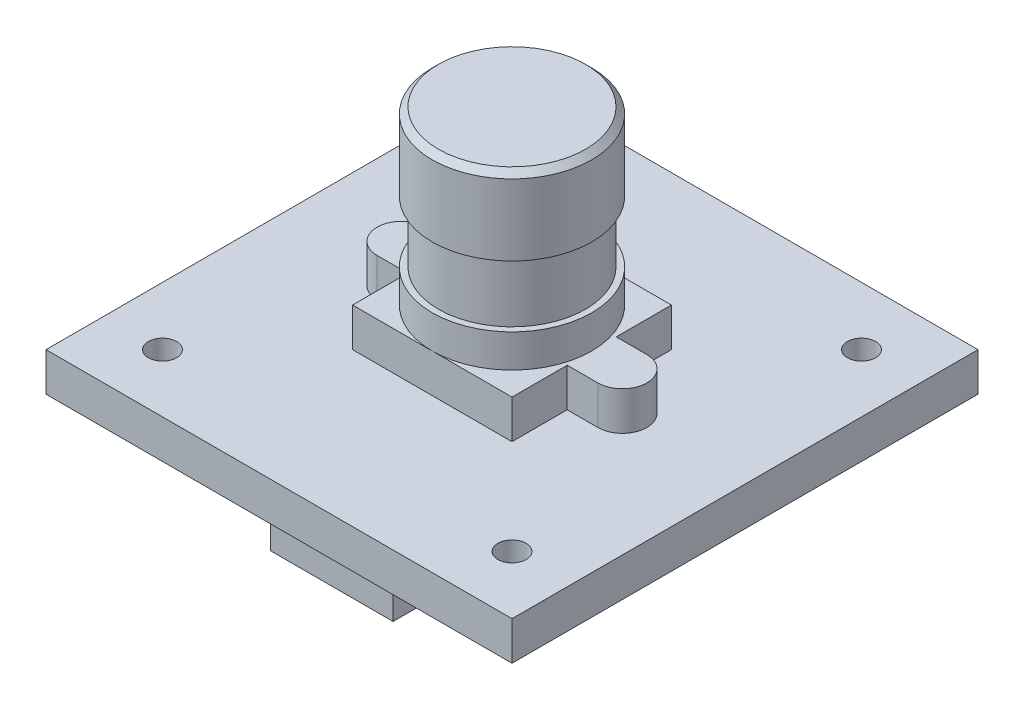
from build123d import *

# Parameters (mm, degrees)
SKETCH_2_W          = 38
SKETCH_2_H          = 38
SKETCH_2_R          = 1.15
EXTRUDE_1_DEPTH     = 3.15
EXTRUDE_START       = 3.15
SKETCH_3_W          = 13
SKETCH_3_H          = 13
EXTRUDE_2_DEPTH     = 3.15
EXTRUDE_START_2     = 6.3
SKETCH_4_R          = 6.5
EXTRUDE_3_DEPTH     = 14
CUT_EXTRUDE_START   = 9
SKETCH_5_R          = 32.561017026
SKETCH_5_R_2        = 6
CUT_EXTRUDE_1_DEPTH = 5
SKETCH_6_W          = 10
SKETCH_6_H          = 4.7
EXTRUDE_4_DEPTH     = 6.2
CHAMFER_1_SIZE      = 0.5


with BuildPart() as part:
    # 草图2 → 凸台-拉伸1 (new body)
    with BuildSketch(Plane(origin=(0, 0, 0), x_dir=(1, 0, 0), z_dir=(0, 1, 0))):
        Rectangle(SKETCH_2_W, SKETCH_2_H)
        with Locations((14.25, 14.25)):
            Circle(SKETCH_2_R, mode=Mode.SUBTRACT)
        with Locations((-14.25, 14.25)):
            Circle(SKETCH_2_R, mode=Mode.SUBTRACT)
        with Locations((14.25, -14.25)):
            Circle(SKETCH_2_R, mode=Mode.SUBTRACT)
        with Locations((-14.25, -14.25)):
            Circle(SKETCH_2_R, mode=Mode.SUBTRACT)
    extrude(amount=EXTRUDE_1_DEPTH)

    # 草图3 → 凸台-拉伸2 (add)
    with BuildSketch(Plane(origin=(0, 0, 0), x_dir=(1, 0, 0), z_dir=(0, 1, 0)).offset(EXTRUDE_START)):
        with BuildLine():
            Line((-6.5, -2), (-6.5, 2))
            Line((-6.5, 2), (-9, 2))
            ThreePointArc((-9, 2), (-11, 0), (-9, -2))
            Line((-9, -2), (-6.5, -2))
        make_face()
        Rectangle(SKETCH_3_W, SKETCH_3_H)
        with BuildLine():
            ThreePointArc((9, -2), (11, 0), (9, 2))
            Line((9, 2), (6.5, 2))
            Line((6.5, 2), (6.5, -2))
            Line((6.5, -2), (9, -2))
        make_face()
    extrude(amount=EXTRUDE_2_DEPTH)

    # 草图4 → 凸台-拉伸3 (add)
    with BuildSketch(Plane(origin=(0, 0, 0), x_dir=(1, 0, 0), z_dir=(0, 1, 0)).offset(EXTRUDE_START_2)):
        Circle(SKETCH_4_R)
    extrude(amount=EXTRUDE_3_DEPTH)

    # 草图5 → 切除-拉伸1 (cut)
    with BuildSketch(Plane(origin=(0, 0, 0), x_dir=(1, 0, 0), z_dir=(0, 1, 0)).offset(CUT_EXTRUDE_START)):
        Circle(SKETCH_5_R)
        Circle(SKETCH_5_R_2, mode=Mode.SUBTRACT)
    extrude(amount=CUT_EXTRUDE_1_DEPTH, mode=Mode.SUBTRACT)

    # 草图6 → 凸台-拉伸4 (add)
    with BuildSketch(Plane(origin=(0, 0, 0), x_dir=(1, 0, 0), z_dir=(0, 1, 0))):
        with Locations((0, -12.35)):
            Rectangle(SKETCH_6_W, SKETCH_6_H)
    extrude(amount=-EXTRUDE_4_DEPTH)

    # 倒角1
    chamfer_1_edges = [part.edges().sort_by_distance(p)[0] for p in [
        (-6.5, 20.3, 0),
    ]]
    chamfer(chamfer_1_edges, length=CHAMFER_1_SIZE)


solid = part.part
